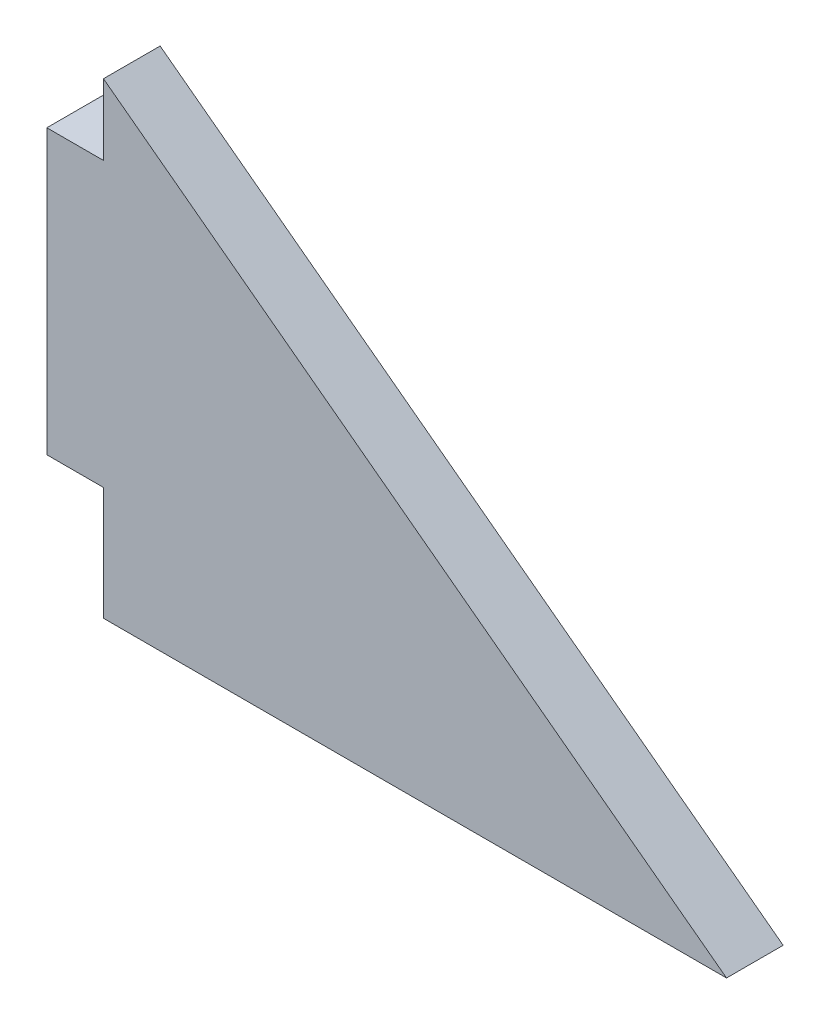
from build123d import *

# Parameters (mm, degrees)
EXTRUDE_1_DEPTH = 2


with BuildPart() as part:
    # ｽｹｯﾁ1 → ﾎﾞｽ - 押し出し1 (new body)
    with BuildSketch(Plane.XY):
        Polygon((0, 0), (0, 10), (2, 10), (2, 12.5), (24, -4), (2, -4), (2, 0), align=None)
    extrude(amount=EXTRUDE_1_DEPTH)


solid = part.part
